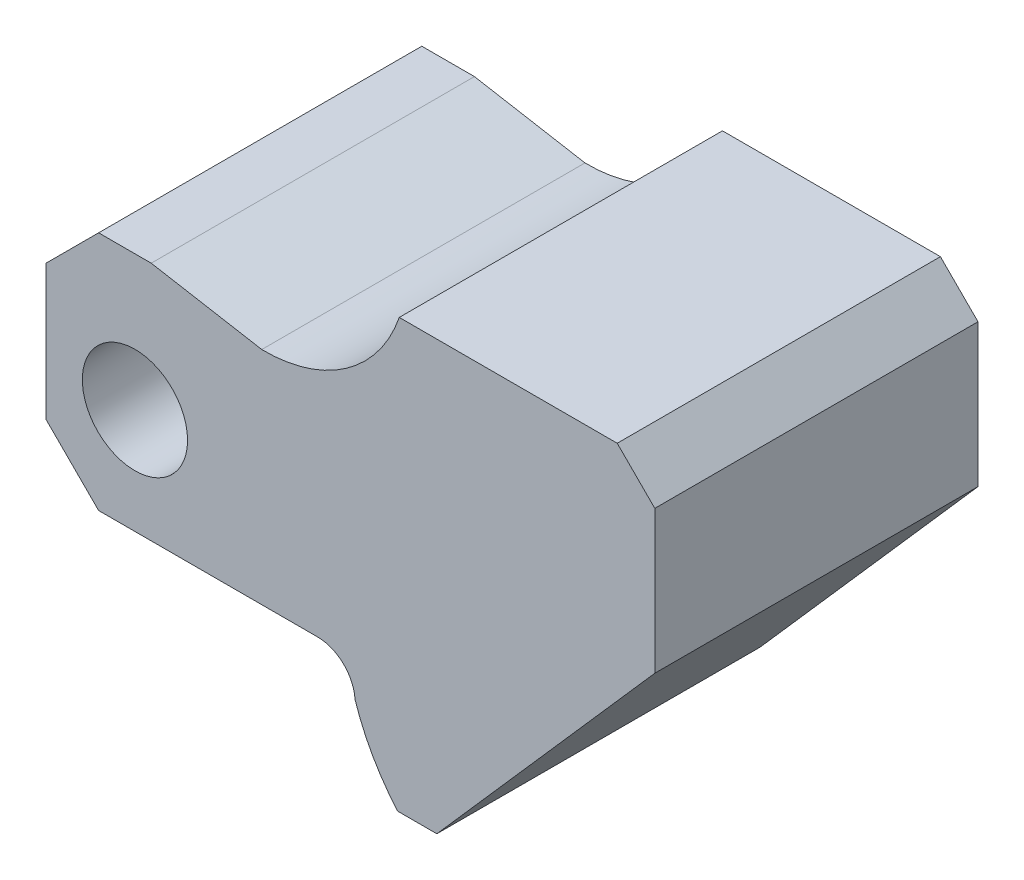
from build123d import *

# Parameters (mm, degrees)
BOSS_EXTRU_1_DEPTH      = 43
ESQUISSE2_R             = 7
ENL_V_MAT_EXTRU_1_DEPTH = 43


with BuildPart() as part:
    # Esquisse1 → Boss.-Extru.1 (new body)
    with BuildSketch(Plane.XY):
        with BuildLine():
            Line((71.055498862, 42.585779817), (100.055498862, 42.585779817))
            Line((100.055498862, 42.585779817), (105.055498862, 37.585779817))
            Line((105.055498862, 37.585779817), (105.055498862, 18.585779817))
            Line((105.055498862, 18.585779817), (76.055498862, -14.414220183))
            Line((76.055498862, -14.414220183), (70.843566259, -14.414220183))
            ThreePointArc((70.843566259, -14.414220183), (67.503369178, -9.678966252), (65.171321088, -4.374147872))
            ThreePointArc((65.171321088, -4.374147872), (63.610652231, -1.028725087), (60.179844427, 0.334029003))
            Line((60.179844427, 0.334029003), (31.055498862, 0.334029003))
            Line((31.055498862, 0.334029003), (24.055498862, 7.334029003))
            Line((24.055498862, 7.334029003), (24.055498862, 25.334029003))
            Line((24.055498862, 25.334029003), (31.055498862, 32.334029003))
            Line((31.055498862, 32.334029003), (38.055498862, 32.334029003))
            Line((38.055498862, 32.334029003), (52.765077496, 29.740333415))
            ThreePointArc((52.765077496, 29.740333415), (63.998851376, 33.189185585), (71.055498862, 42.585779817))
        make_face()
    extrude(amount=BOSS_EXTRU_1_DEPTH)

    # Esquisse2 → Enlèv. mat.-Extru.1 (cut)
    with BuildSketch(Plane.XY.offset(43)):
        with Locations((35.888461386, 14.334029003)):
            Circle(ESQUISSE2_R)
    extrude(amount=-ENL_V_MAT_EXTRU_1_DEPTH, mode=Mode.SUBTRACT)


solid = part.part
